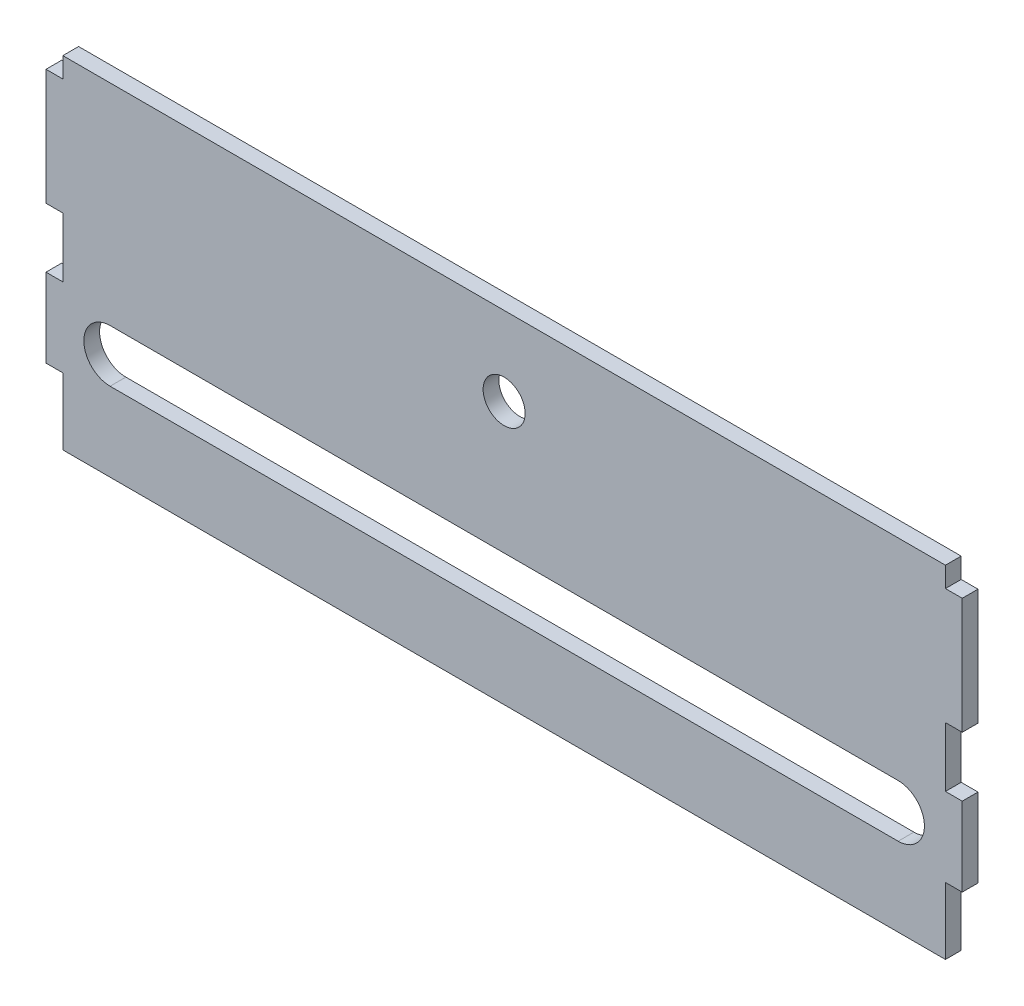
from build123d import *

# Parameters (mm, degrees)
CROQUIS1_R              = 4
SALIENTE_EXTRUIR1_DEPTH = 3
CROQUIS2_W              = 183.661988175
CROQUIS2_H              = 35
CORTAR_EXTRUIR1_DEPTH   = 4


with BuildPart() as part:
    # Croquis1 → Saliente-Extruir1 (new body)
    with BuildSketch(Plane.XY):
        Polygon((-84, 37.295390898), (-87.2, 37.295390898), (-87.2, 22.295390898), (-84, 22.295390898), (-84, 11.147890898), (-87.2, 11.147890898), (-87.2, -10.945390898), (-84, -10.945390898), (-84, -22.295390898), (-87.2, -22.295390898), (-87.2, -37.295390898), (-84, -37.295390898), (-84, -50), (84, -50), (84, -37.295390898), (87.2, -37.295390898), (87.2, -22.295390898), (84, -22.295390898), (84, -10.945390898), (87.2, -10.945390898), (87.2, 11.147890898), (84, 11.147890898), (84, 22.295390898), (87.2, 22.295390898), (87.2, 37.295390898), (84, 37.295390898), (84, 50), (-84, 50), align=None)
        Circle(CROQUIS1_R, mode=Mode.SUBTRACT)
        with BuildLine():
            Line((-75, -25), (75, -25))
            ThreePointArc((75, -25), (80, -30), (75, -35))
            Line((75, -35), (-75, -35))
            ThreePointArc((-75, -35), (-80, -30), (-75, -25))
        make_face(mode=Mode.SUBTRACT)
        with BuildLine():
            Line((-75, 25), (75, 25))
            ThreePointArc((75, 25), (80, 30), (75, 35))
            Line((75, 35), (-75, 35))
            ThreePointArc((-75, 35), (-80, 30), (-75, 25))
        make_face(mode=Mode.SUBTRACT)
    extrude(amount=SALIENTE_EXTRUIR1_DEPTH)

    # Croquis2 → Cortar-Extruir1 (cut, through all)
    with BuildSketch(Plane.XY.offset(3)):
        with Locations((-0.5645348, 32.5)):
            Rectangle(CROQUIS2_W, CROQUIS2_H)
    extrude(amount=-CORTAR_EXTRUIR1_DEPTH, mode=Mode.SUBTRACT)


solid = part.part
